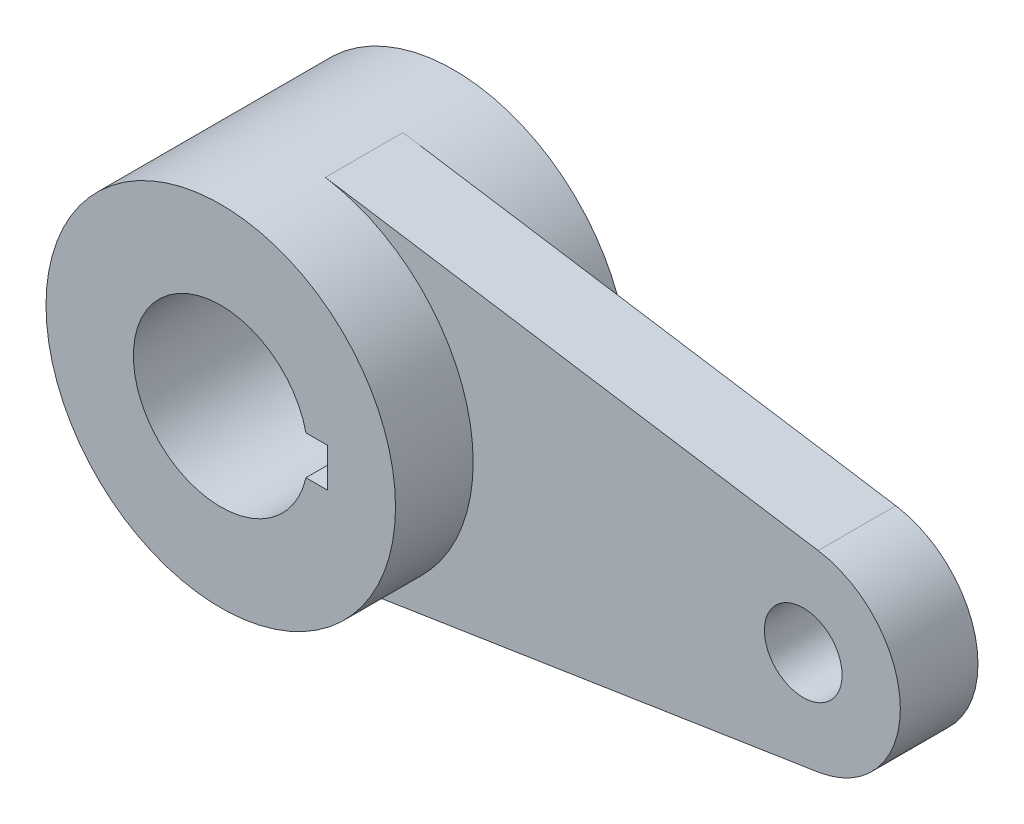
from build123d import *

# Parameters (mm, degrees)
BOSS_EXTRUDE3_DEPTH      = 6.35
BOSS_EXTRUDE3_DEPTH_BACK = 6.35
BOSS_EXTRUDE4_DEPTH      = 19.05
BOSS_EXTRUDE4_DEPTH_BACK = 19.05
SKETCH3_R                = 28.575
SKETCH4_R                = 6.35
CUT_EXTRUDE1_DEPTH       = 106.589636092
SKETCH5_R                = 14.2875
CUT_EXTRUDE2_DEPTH       = 110.341763522
SKETCH6_W                = 17.4752
SKETCH6_H                = 6.35
CUT_EXTRUDE3_DEPTH       = 110.341763522


with BuildPart() as part:
    # Sketch1 → Boss-Extrude3 (new, two sides: drawn at the far end of the back side and taken through both)
    with BuildSketch(Plane.XY.offset(-BOSS_EXTRUDE3_DEPTH_BACK)):
        with BuildLine():
            Line((4.396153846, -28.234809303), (84.992307692, -15.686005168))
            ThreePointArc((84.992307692, -15.686005168), (98.425, 0), (84.992307692, 15.686005168))
            Line((84.992307692, 15.686005168), (4.396153846, 28.234809303))
            ThreePointArc((4.396153846, 28.234809303), (28.575, 0), (4.396153846, -28.234809303))
        make_face()
    extrude(amount=BOSS_EXTRUDE3_DEPTH + BOSS_EXTRUDE3_DEPTH_BACK)

    # Sketch3 → Boss-Extrude4 (add, two sides: drawn at the far end of the back side and taken through both)
    with BuildSketch(Plane.XY.offset(-BOSS_EXTRUDE4_DEPTH_BACK)):
        Circle(SKETCH3_R)
    extrude(amount=BOSS_EXTRUDE4_DEPTH + BOSS_EXTRUDE4_DEPTH_BACK)

    # Sketch4 → Cut-Extrude1 (cut, through all)
    with BuildSketch(Plane.XY.offset(6.35)):
        with Locations((82.55, 0)):
            Circle(SKETCH4_R)
    extrude(amount=-CUT_EXTRUDE1_DEPTH, mode=Mode.SUBTRACT)

    # Sketch5 → Cut-Extrude2 (cut, through all)
    with BuildSketch(Plane.XY.offset(19.05)):
        Circle(SKETCH5_R)
    extrude(amount=-CUT_EXTRUDE2_DEPTH, mode=Mode.SUBTRACT)

    # Sketch6 → Cut-Extrude3 (cut, through all)
    with BuildSketch(Plane.XY.offset(19.05)):
        with Locations((8.7376, 0)):
            Rectangle(SKETCH6_W, SKETCH6_H)
    extrude(amount=-CUT_EXTRUDE3_DEPTH, mode=Mode.SUBTRACT)


solid = part.part
